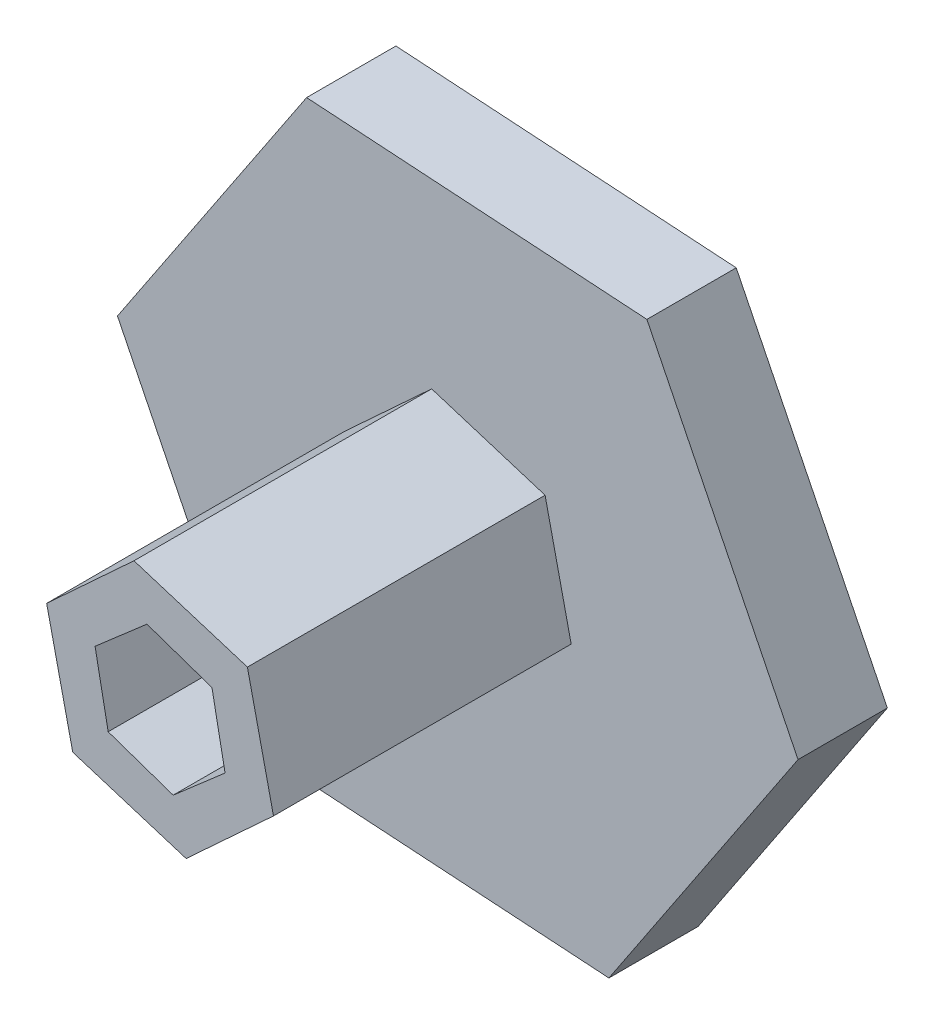
from build123d import *

# Parameters (mm, degrees)
BOSS_EXTRUDE1_DEPTH      = 7.62
BOSS_EXTRUDE2_DEPTH      = 25.4
BOSS_EXTRUDE2_DEPTH_BACK = 7.62
BOSS_EXTRUDE3_DEPTH      = 7.62


with BuildPart() as part:
    # Sketch1 → Boss-Extrude1 (new body)
    with BuildSketch(Plane.XY):
        Polygon((29.034826066, -1.872543671), (16.139083421, 24.208625132), (-12.895742644, 26.081168803), (-29.034826066, 1.872543671), (-16.139083421, -24.208625132), (12.895742644, -26.081168803), align=None)
        Polygon((-2.225944347, 9.889162812), (7.451294044, 6.872305758), (9.677238391, -3.016857054), (2.225944347, -9.889162812), (-7.451294044, -6.872305758), (-9.677238391, 3.016857054), align=None, mode=Mode.SUBTRACT)
    extrude(amount=-BOSS_EXTRUDE1_DEPTH)

    # Sketch1_3 → Boss-Extrude2 (add, two sides: drawn at the far end of the back side and taken through both)
    with BuildSketch(Plane.XY.offset(-BOSS_EXTRUDE2_DEPTH_BACK)):
        Polygon((9.677238391, -3.016857054), (7.451294044, 6.872305758), (-2.225944347, 9.889162812), (-9.677238391, 3.016857054), (-7.451294044, -6.872305758), (2.225944347, -9.889162812), align=None)
        Polygon((-1.117880084, 5.758374549), (4.427958602, 3.847299826), (5.545838686, -1.911074723), (1.117880084, -5.758374549), (-4.427958602, -3.847299826), (-5.545838686, 1.911074723), align=None, mode=Mode.SUBTRACT)
    extrude(amount=BOSS_EXTRUDE2_DEPTH + BOSS_EXTRUDE2_DEPTH_BACK)

    # Sketch2 → Boss-Extrude3 (add)
    with BuildSketch(Plane(origin=(0, 0, -7.62), x_dir=(-1, 0, 0), z_dir=(0, 0, -1))):
        Polygon((1.117880084, 5.758374549), (-4.427958602, 3.847299826), (-5.545838686, -1.911074723), (-1.117880084, -5.758374549), (4.427958602, -3.847299826), (5.545838686, 1.911074723), align=None)
    extrude(amount=-BOSS_EXTRUDE3_DEPTH)


solid = part.part
